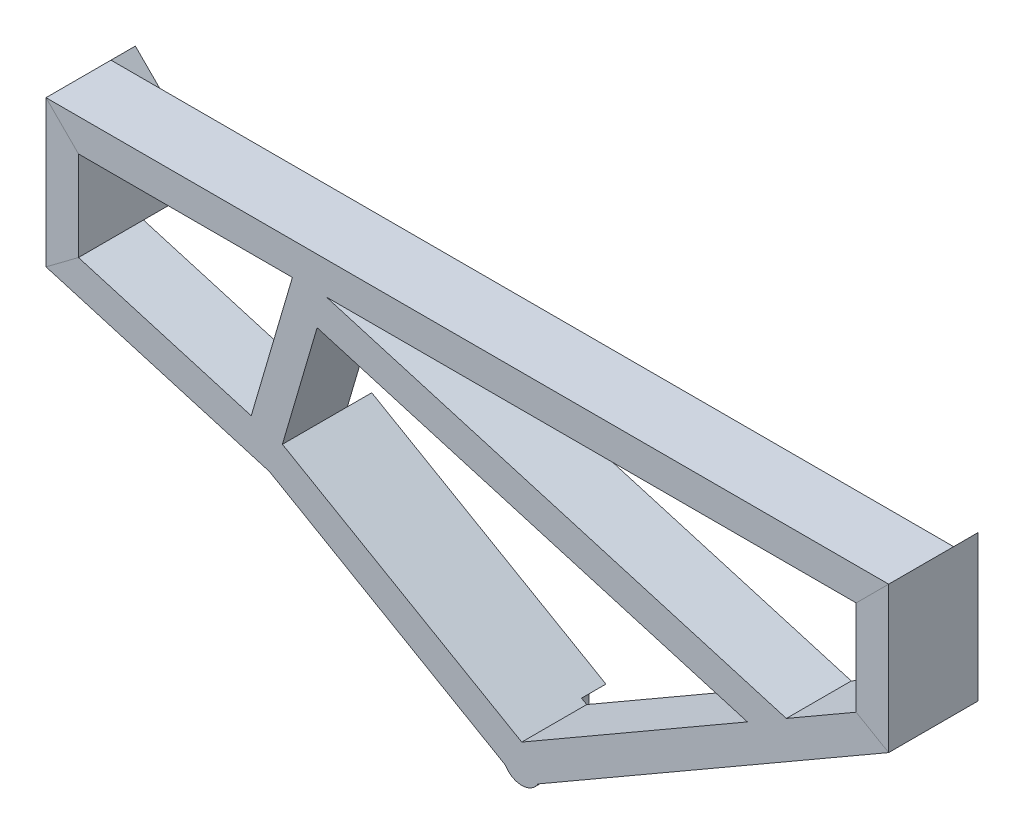
from build123d import *

# Parameters (mm, degrees)
SKETCH_6_W          = 80
SKETCH_6_H          = 40
SKETCH_6_W_2        = 76
SKETCH_6_H_2        = 36
SKETCH_14_W         = 40
SKETCH_14_H         = 80
EXTRUDE_1_DEPTH     = 194
SKETCH_15_W         = 80
SKETCH_15_H         = 40
EXTRUDE_2_DEPTH     = 595
EXTRUDE_3_DEPTH     = 30
SKETCH_17_R         = 23.094010768
EXTRUDE_4_DEPTH     = 110
SKETCH_18_R         = 27.5
SKETCH_18_R_2       = 23.094010768
CUT_EXTRUDE_1_DEPTH = 30
SKETCH_22_R         = 23.094010768
CUT_EXTRUDE_3_DEPTH = 30
CUT_EXTRUDE_4_DEPTH = 10
FILLET_1_R          = 0.5


with BuildPart() as part:
    # По траектории13: sweep along a curve in space
    with BuildLine() as sweep_13_path:
        Line((0, 0, 0), (1000, 0, 0))
        Line((1000, 0, 0), (1000, -150, 0))
        Line((1000, -150, 0), (566.987298108, -400, 0))
        Line((566.987298108, -400, 0), (263.878406783, -225, 0))
        Line((263.878406783, -225, 0), (0, -147.584326952, 0))
        Line((0, -147.584326952, 0), (0, 0, 0))
    # Эскиз6 → По траектории13 (sweep)
    with BuildSketch(Plane(origin=(0, 0, 0), x_dir=(0, 0, -1), z_dir=(1, 0, 0))):
        with Locations((-0.551773823, -1.216505436)):
            Rectangle(SKETCH_6_W, SKETCH_6_H)
        with Locations((-0.551773823, -1.216505436)):
            Rectangle(SKETCH_6_W_2, SKETCH_6_H_2, mode=Mode.SUBTRACT)
    sweep(path=sweep_13_path.line, transition=Transition.RIGHT)

    # Эскиз14 → Бобышка-Вытянуть1 (add)
    with BuildSketch(Plane(origin=(-33.89376203, -115.529989888, 0), x_dir=(0.9595578428480989, -0.2815115383580276, 0), z_dir=(0.2815115383580276, 0.9595578428480989, 0))):
        with Locations((299.085913187, -0.551773823)):
            Rectangle(SKETCH_14_W, SKETCH_14_H)
    extrude(amount=EXTRUDE_1_DEPTH)

    # Эскиз15 → Бобышка-Вытянуть2 (add)
    with BuildSketch(Plane(origin=(306.181390541, -89.82636629, 0), x_dir=(0, 0, -1), z_dir=(0.9595578428480989, -0.28151153835802767, 0))):
        with Locations((-0.551773823, 51.50143726)):
            Rectangle(SKETCH_15_W, SKETCH_15_H)
    extrude(amount=EXTRUDE_2_DEPTH)

    # Эскиз16 → Бобышка-Вытянуть3 (add)
    with BuildSketch(Plane(origin=(0, 0, -39.448226177), x_dir=(-1, 0, 0), z_dir=(0, 0, -1))):
        Polygon((18.783494564, 18.783494564), (18.783494564, -161.648850746), (-21.216505436, -131.698036755), (-21.216505436, -21.216505436), align=None)
        Polygon((-272.28762851, -205.356356178), (-256.433515773, -242.391001456), (-566.987298108, -421.689311285), (-566.987298108, -375.50128975), align=None)
        Polygon((-1018.783494564, 18.783494564), (-978.783494564, -21.216505436), (-978.783494564, -137.750644875), (-1018.783494564, -160.844655643), align=None)
    extrude(amount=EXTRUDE_3_DEPTH)

    # Эскиз17 → Бобышка-Вытянуть4 (add)
    with BuildSketch(Plane(origin=(0, 0, -69.448226177), x_dir=(-1, 0, 0), z_dir=(0, 0, -1))):
        with Locations((-566.987298108, -398.595300518)):
            Circle(SKETCH_17_R)
    extrude(amount=-EXTRUDE_4_DEPTH)

    # Эскиз18 → Вырез-Вытянуть1 (cut)
    with BuildSketch(Plane(origin=(0, 0, -69.448226177), x_dir=(-1, 0, 0), z_dir=(0, 0, -1))):
        with Locations((-566.987298108, -398.595300518)):
            Circle(SKETCH_18_R)
        with Locations((-566.987298108, -398.595300518)):
            Circle(SKETCH_18_R_2, mode=Mode.SUBTRACT)
    extrude(amount=-CUT_EXTRUDE_1_DEPTH, mode=Mode.SUBTRACT)

    # Эскиз22 → Вырез-Вытянуть3 (cut)
    with BuildSketch(Plane(origin=(0, 0, -69.448226177), x_dir=(-1, 0, 0), z_dir=(0, 0, -1))):
        with Locations((-566.987298108, -398.595300518)):
            Circle(SKETCH_22_R)
    extrude(amount=-CUT_EXTRUDE_3_DEPTH, mode=Mode.SUBTRACT)

    # Эскиз23 → Вырез-Вытянуть4 (cut)
    with BuildSketch(Plane(origin=(0, 0, -39.448226177), x_dir=(-1, 0, 0), z_dir=(0, 0, -1))):
        with BuildLine():
            ThreePointArc((-549.487298108, -398.595300518), (-554.612929437, -386.220931847), (-566.987298108, -381.095300518))
            Line((-566.987298108, -381.095300518), (-566.987298108, -416.095300518))
            ThreePointArc((-566.987298108, -416.095300518), (-554.612929437, -410.969669189), (-549.487298108, -398.595300518))
        make_face()
        with BuildLine():
            Line((-566.987298108, -416.095300518), (-566.987298108, -381.095300518))
            ThreePointArc((-566.987298108, -381.095300518), (-584.487298108, -398.595300518), (-566.987298108, -416.095300518))
        make_face()
    extrude(amount=-CUT_EXTRUDE_4_DEPTH, mode=Mode.SUBTRACT)

    # Скругление1
    fillet_1_edges = [part.edges().sort_by_distance(p)[0] for p in [
        (566.987298108, -416.095300518, -39.448226177),
    ]]
    fillet(fillet_1_edges, radius=FILLET_1_R)


solid = part.part
